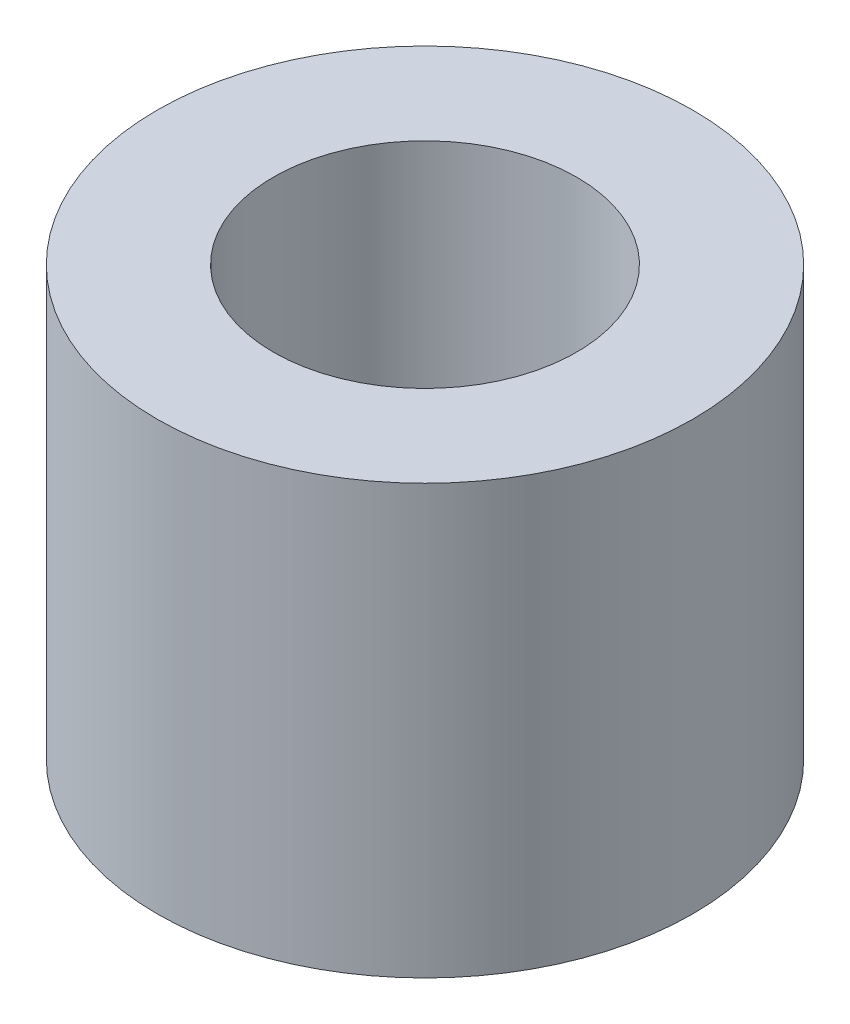
from build123d import *

# Parameters (mm, degrees)
SKETCH1_R           = 3.96875
SKETCH1_R_2         = 2.2479
BOSS_EXTRUDE1_DEPTH = 6.35


with BuildPart() as part:
    # Sketch1 → Boss-Extrude1 (new body)
    with BuildSketch(Plane(origin=(0, 0, 0), x_dir=(1, 0, 0), z_dir=(0, 1, 0))):
        Circle(SKETCH1_R)
        Circle(SKETCH1_R_2, mode=Mode.SUBTRACT)
    extrude(amount=BOSS_EXTRUDE1_DEPTH)


solid = part.part
